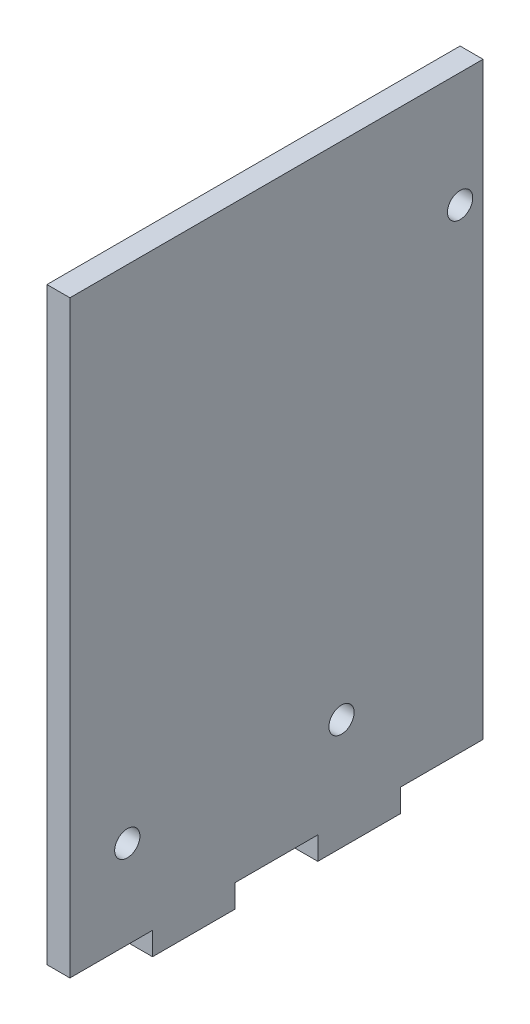
from build123d import *

# Parameters (mm, degrees)
SKETCH1_R           = 1.65
BOSS_EXTRUDE1_DEPTH = 3


with BuildPart() as part:
    # Sketch1 → Boss-Extrude1 (new body)
    with BuildSketch(Plane(origin=(0, 0, 0), x_dir=(0, 0, -1), z_dir=(1, 0, 0))):
        Polygon((-27, 40), (27, 40), (27, -37), (16.2, -37), (16.2, -40), (5.4, -40), (5.4, -37), (-5.4, -37), (-5.4, -40), (-16.2, -40), (-16.2, -37), (-27, -37), align=None)
        with Locations((8.5, -25.5)):
            Circle(SKETCH1_R, mode=Mode.SUBTRACT)
        with Locations((-19.5, -25.5)):
            Circle(SKETCH1_R, mode=Mode.SUBTRACT)
        with Locations((24, 25)):
            Circle(SKETCH1_R, mode=Mode.SUBTRACT)
    extrude(amount=BOSS_EXTRUDE1_DEPTH)


solid = part.part
